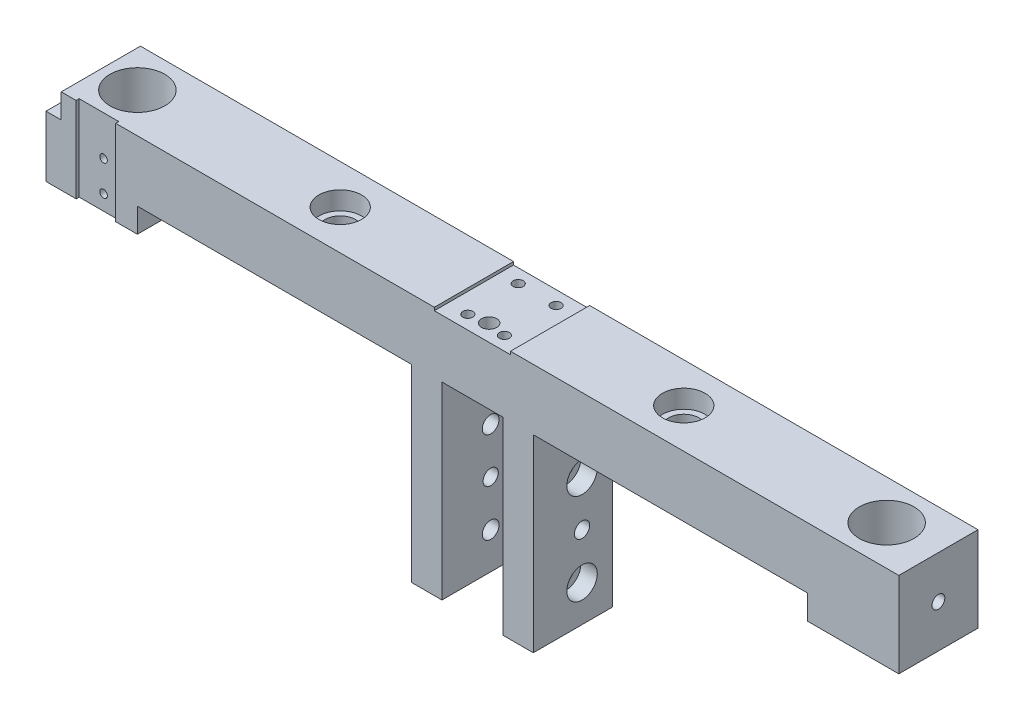
from build123d import *

# Parameters (mm, degrees)
SKETCH_1_W                    = 280
SKETCH_1_H                    = 35
EXTRUDE_1_DEPTH               = 26
SKETCH_3_R                    = 9
CUT_EXTRUDE_1_DEPTH           = 36
SKETCH_4_W                    = 25
SKETCH_4_H                    = 26
CUT_EXTRUDE_2_DEPTH           = 1
HOLE_WIZARD_M4_1_D            = 3.3
HOLE_WIZARD_M4_1_DEPTH        = 10.1
HOLE_WIZARD_M4_1_TIP          = 0.991420021
SKETCH_7_W                    = 220
SKETCH_7_H                    = 15
CUT_EXTRUDE_3_DEPTH           = 27
SKETCH_8_W                    = 40
SKETCH_8_H                    = 26
EXTRUDE_2_DEPTH               = 35
SKETCH_15_W                   = 58.430685067
SKETCH_15_H                   = 44.376242578
CUT_EXTRUDE_7_DEPTH           = 3
SKETCH_17_W                   = 40
SKETCH_17_H                   = 26
EXTRUDE_4_DEPTH               = 30
SKETCH_18_W                   = 20
SKETCH_18_H                   = 62
CUT_EXTRUDE_8_DEPTH           = 27
SKETCH_19_W                   = 30
SKETCH_19_H                   = 26
CUT_EXTRUDE_11_DEPTH          = 7
HOLE_WIZARD_M5_1_2_AT_2_COUNT = 2
HOLE_WIZARD_M5_1_2_AT_2_PITCH = 30
CHAMFER_1_SIZE                = 5
CHAMFER_1_SIZE2               = 2.886751346
CHAMFER_2_SIZE                = 5
CHAMFER_2_SIZE2               = 2.886751346
SKETCH_25_R                   = 2.5
CUT_EXTRUDE_12_DEPTH          = 21.0000001
SKETCH_26_R                   = 2.5
CUT_EXTRUDE_13_DEPTH          = 161.0000001
SKETCH_27_R                   = 5
CUT_EXTRUDE_14_DEPTH          = 83
SKETCH_28_R                   = 7
CUT_EXTRUDE_15_DEPTH          = 6
SKETCH_31_W                   = 13
SKETCH_31_H                   = 28
CUT_EXTRUDE_16_DEPTH          = 1
HOLE_WIZARD_M3_1_D            = 2.5
HOLE_WIZARD_M3_1_DEPTH        = 7.5
HOLE_WIZARD_M3_1_TIP          = 0.751075774
SKETCH_34_W                   = 5
SKETCH_34_H                   = 8
CUT_EXTRUDE_17_DEPTH          = 27


with BuildPart() as part:
    # 草图1 → 凸台-拉伸1 (new body)
    with BuildSketch(Plane.XY):
        with Locations((140, 17.5)):
            Rectangle(SKETCH_1_W, SKETCH_1_H)
    extrude(amount=EXTRUDE_1_DEPTH)

    # 草图3 → 切除-拉伸1 (cut, through all)
    with BuildSketch(Plane.XZ):
        with Locations((17, 13)):
            Circle(SKETCH_3_R)
        with Locations((263, 13)):
            Circle(SKETCH_3_R)
    extrude(amount=-CUT_EXTRUDE_1_DEPTH, mode=Mode.SUBTRACT)

    # 草图4 → 切除-拉伸2 (cut)
    with BuildSketch(Plane(origin=(0, 35, 0), x_dir=(1, 0, 0), z_dir=(0, 1, 0))):
        with Locations((140, -13)):
            Rectangle(SKETCH_4_W, SKETCH_4_H)
    extrude(amount=-CUT_EXTRUDE_2_DEPTH, mode=Mode.SUBTRACT)

    # M4 螺纹孔1
    with Locations(Plane(origin=(0, 34, 0), x_dir=(1, 0, 0), z_dir=(0, 1, 0))):
        with Locations((146, -21.5), (134, -21.5), (146, -4.5), (133.546958493, -4.5)):
            Hole(HOLE_WIZARD_M4_1_D / 2, depth=HOLE_WIZARD_M4_1_DEPTH)
            with Locations((0, 0, -(HOLE_WIZARD_M4_1_DEPTH + HOLE_WIZARD_M4_1_TIP / 2))):  # 118° drill point
                Cone(0, HOLE_WIZARD_M4_1_D / 2, HOLE_WIZARD_M4_1_TIP, mode=Mode.SUBTRACT)

    # 草图7 → 切除-拉伸3 (cut, through all)
    with BuildSketch(Plane.XY.offset(26)):
        with Locations((140, 7.5)):
            Rectangle(SKETCH_7_W, SKETCH_7_H)
    extrude(amount=-CUT_EXTRUDE_3_DEPTH, mode=Mode.SUBTRACT)

    # 草图8 → 凸台-拉伸2 (add)
    with BuildSketch(Plane.XZ.offset(-15)):
        with Locations((140, 13)):
            Rectangle(SKETCH_8_W, SKETCH_8_H)
    extrude(amount=EXTRUDE_2_DEPTH)

    # 草图15 → 切除-拉伸7 (cut)
    with BuildSketch(Plane.XZ.offset(20)):
        with Locations((130.784657466, 3.811878711)):
            Rectangle(SKETCH_15_W, SKETCH_15_H)
    extrude(amount=-CUT_EXTRUDE_7_DEPTH, mode=Mode.SUBTRACT)

    # 草图17 → 凸台-拉伸4 (add)
    with BuildSketch(Plane.XZ.offset(17)):
        with Locations((140, 13)):
            Rectangle(SKETCH_17_W, SKETCH_17_H)
    extrude(amount=EXTRUDE_4_DEPTH)

    # 草图18 → 切除-拉伸8 (cut, through all)
    with BuildSketch(Plane(origin=(0, 0, 0), x_dir=(-1, 0, 0), z_dir=(0, 0, -1))):
        with Locations((-140, -16)):
            Rectangle(SKETCH_18_W, SKETCH_18_H)
    extrude(amount=-CUT_EXTRUDE_8_DEPTH, mode=Mode.SUBTRACT)

    # 草图19 → 切除-拉伸11 (cut)
    with BuildSketch(Plane.XZ):
        with Locations((265, 13)):
            Rectangle(SKETCH_19_W, SKETCH_19_H)
        with Locations((15, 13)):
            Rectangle(SKETCH_19_W, SKETCH_19_H)
    extrude(amount=-CUT_EXTRUDE_11_DEPTH, mode=Mode.SUBTRACT)

    # 草图21 → Hole Wizard M5 _1 (revolve, cut)
    with BuildSketch(Plane(origin=(280, 21, 13), x_dir=(0, 0, -1), z_dir=(0, 1, 0))):
        Polygon((0, 0), (0, 13.6618073), (2.1, 12.4), (2.1, 0), align=None)
    hole_wizard_m5_1 = revolve(axis=Axis((286.35, 21, 13), (-1, 0, 0)), mode=Mode.SUBTRACT)

    # 镜向1: Hole Wizard M5 _1 across plane
    add(hole_wizard_m5_1.mirror(Plane.ZY.offset(-140)), mode=Mode.SUBTRACT)

    # 草图24 → Hole Wizard M5 _1 2 (revolve, cut)
    with BuildSketch(Plane(origin=(160, -35, 10), x_dir=(0, 0, -1), z_dir=(0, 1, 0))):
        Polygon((0, 0), (0, 14.052366702), (2.75, 12.4), (2.75, 5.4), (5, 5.4), (5, 0), align=None)
    hole_wizard_m5_1_2 = revolve(axis=Axis((166.35, -35, 10), (-1, 0, 0)), mode=Mode.SUBTRACT)

    # Hole Wizard M5 _1 2 at 2: Hole Wizard M5 _1 2 ×2
    with Locations(*[(0, i * HOLE_WIZARD_M5_1_2_AT_2_PITCH, 0) for i in range(1, HOLE_WIZARD_M5_1_2_AT_2_COUNT)]):
        add(hole_wizard_m5_1_2, mode=Mode.SUBTRACT)

    # 倒角1
    chamfer_1_edges = [part.edges().sort_by_distance(p)[0] for p in [
        (150, -16, 0),
    ]]
    chamfer_1_side = [part.faces().sort_by_distance(p)[0] for p in [
        (150, -15.878511748, 13.091116189),
    ]]
    chamfer(chamfer_1_edges, length=CHAMFER_1_SIZE, length2=CHAMFER_1_SIZE2, reference=chamfer_1_side[0])

    # 倒角2
    chamfer_2_edges = [part.edges().sort_by_distance(p)[0] for p in [
        (130, -16, 0),
    ]]
    chamfer_2_side = [part.faces().sort_by_distance(p)[0] for p in [
        (130, -16, 13),
    ]]
    chamfer(chamfer_2_edges, length=CHAMFER_2_SIZE, length2=CHAMFER_2_SIZE2, reference=chamfer_2_side[0])

    # 镜向2: Hole Wizard M5 _1 2 across plane
    add(hole_wizard_m5_1_2.mirror(Plane.ZY.offset(-140)), mode=Mode.SUBTRACT)

    # 镜向2 copy 1 sketch → 镜向2 copy 1 (revolve, cut)
    with BuildSketch(Plane(origin=(120, -5, 10), x_dir=(0, 0, -1), z_dir=(0, 1, 0))):
        Polygon((0, 0), (0, -14.052366702), (2.75, -12.4), (2.75, -5.4), (5, -5.4), (5, 0), align=None)
    revolve(axis=Axis((113.65, -5, 10), (-1, 0, 0)), mode=Mode.SUBTRACT)

    # 草图25 → 切除-拉伸12 (cut, through all)
    with BuildSketch(Plane.XZ.offset(-15)):
        with Locations((140, 20.49725583)):
            Circle(SKETCH_25_R)
    extrude(amount=-CUT_EXTRUDE_12_DEPTH, mode=Mode.SUBTRACT)

    # 草图26 → 切除-拉伸13 (cut, through all)
    with BuildSketch(Plane.ZY.offset(-120)):
        with Locations((10, -20)):
            Circle(SKETCH_26_R)
    extrude(amount=-CUT_EXTRUDE_13_DEPTH, mode=Mode.SUBTRACT)

    # 草图27 → 切除-拉伸14 (cut, through all)
    with BuildSketch(Plane(origin=(0, 35, 0), x_dir=(1, 0, 0), z_dir=(0, 1, 0))):
        with Locations((196.4, -13)):
            Circle(SKETCH_27_R)
        with Locations((83.6, -13)):
            Circle(SKETCH_27_R)
    extrude(amount=-CUT_EXTRUDE_14_DEPTH, mode=Mode.SUBTRACT)

    # 草图28 → 切除-拉伸15 (cut)
    with BuildSketch(Plane(origin=(0, 35, 0), x_dir=(1, 0, 0), z_dir=(0, 1, 0))):
        with Locations((196.4, -13)):
            Circle(SKETCH_28_R)
        with Locations((83.6, -13)):
            Circle(SKETCH_28_R)
    extrude(amount=-CUT_EXTRUDE_15_DEPTH, mode=Mode.SUBTRACT)

    # 草图31 → 切除-拉伸16 (cut)
    with BuildSketch(Plane.XY.offset(26)):
        with Locations((16.4, 21)):
            Rectangle(SKETCH_31_W, SKETCH_31_H)
    extrude(amount=-CUT_EXTRUDE_16_DEPTH, mode=Mode.SUBTRACT)

    # M3 螺纹孔1
    with Locations(Plane.XY.offset(25)):
        with Locations((17.9, 12), (17.9, 22)):
            Hole(HOLE_WIZARD_M3_1_D / 2, depth=HOLE_WIZARD_M3_1_DEPTH)
            with Locations((0, 0, -(HOLE_WIZARD_M3_1_DEPTH + HOLE_WIZARD_M3_1_TIP / 2))):  # 118° drill point
                Cone(0, HOLE_WIZARD_M3_1_D / 2, HOLE_WIZARD_M3_1_TIP, mode=Mode.SUBTRACT)

    # 草图34 → 切除-拉伸17 (cut, through all)
    with BuildSketch(Plane.XY.offset(26)):
        with Locations((2.5, 31)):
            Rectangle(SKETCH_34_W, SKETCH_34_H)
    extrude(amount=-CUT_EXTRUDE_17_DEPTH, mode=Mode.SUBTRACT)


solid = part.part
